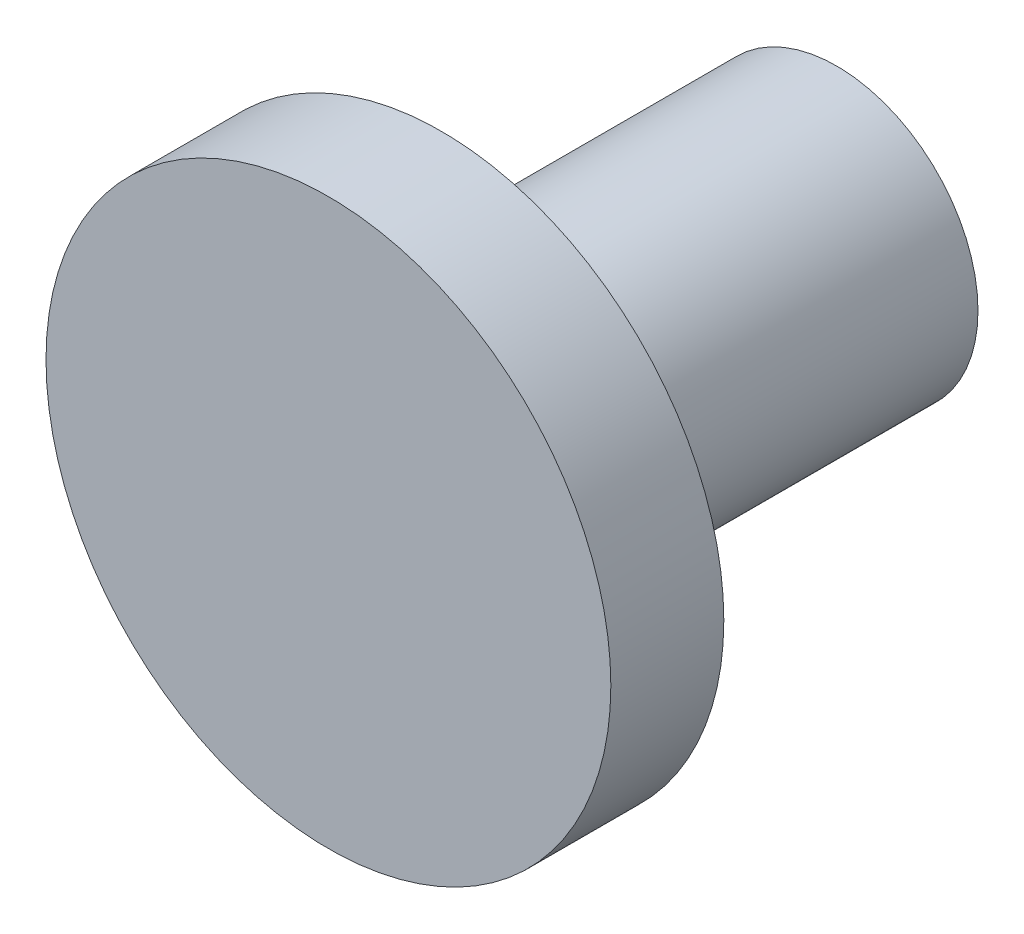
from build123d import *

# Parameters (mm, degrees)
SKETCH_1_R          = 5
EXTRUDE_1_DEPTH     = 18
SKETCH_2_R          = 10
EXTRUDE_2_DEPTH     = 4
SKETCH_3_R          = 1.6
CUT_EXTRUDE_1_DEPTH = 12


with BuildPart() as part:
    # ｽｹｯﾁ1 → ﾎﾞｽ - 押し出し1 (new body)
    with BuildSketch(Plane.XY):
        Circle(SKETCH_1_R)
    extrude(amount=EXTRUDE_1_DEPTH)

    # ｽｹｯﾁ2 → ﾎﾞｽ - 押し出し2 (add)
    with BuildSketch(Plane.XY.offset(18)):
        Circle(SKETCH_2_R)
    extrude(amount=-EXTRUDE_2_DEPTH)

    # ｽｹｯﾁ3 → ｶｯﾄ - 押し出し1 (cut)
    with BuildSketch(Plane(origin=(0, 0, 0), x_dir=(-1, 0, 0), z_dir=(0, 0, -1))):
        Circle(SKETCH_3_R)
    extrude(amount=-CUT_EXTRUDE_1_DEPTH, mode=Mode.SUBTRACT)


solid = part.part
